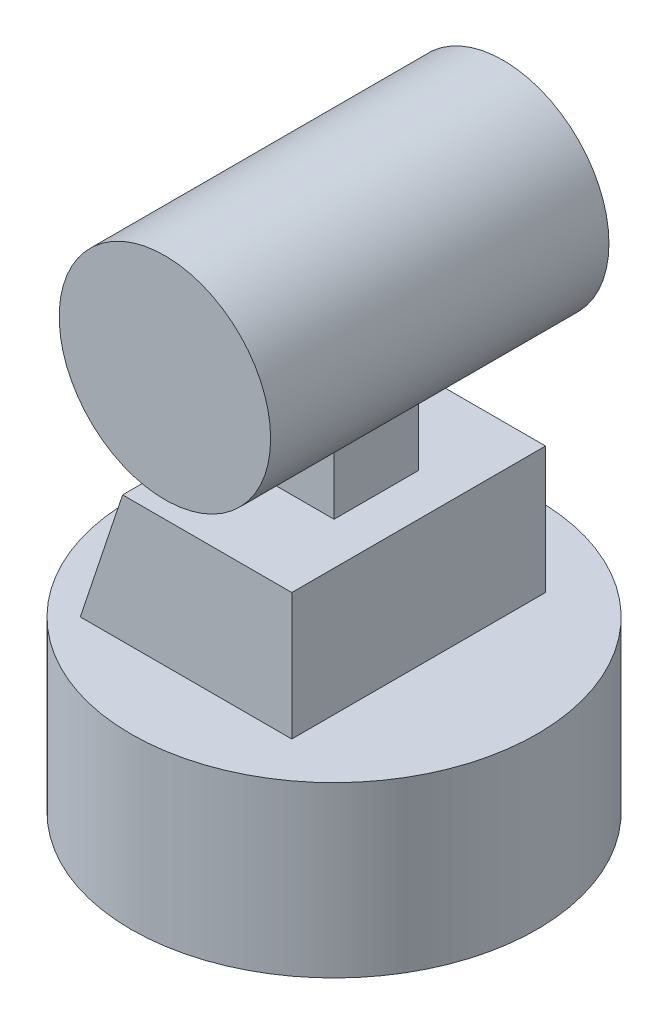
from build123d import *

# Parameters (mm, degrees)
SKETCH1_R           = 24
BOSS_EXTRUDE1_DEPTH = 20
SKETCH4_R           = 12.5
BOSS_EXTRUDE3_DEPTH = 20
BOSS_EXTRUDE5_DEPTH = 15
SKETCH6_W           = 10
SKETCH6_H           = 10
BOSS_EXTRUDE6_DEPTH = 8.043561


with BuildPart() as part:
    # Sketch1 → Boss-Extrude1 (new body)
    with BuildSketch(Plane(origin=(0, 0, 0), x_dir=(1, 0, 0), z_dir=(0, 1, 0))):
        Circle(SKETCH1_R)
    extrude(amount=BOSS_EXTRUDE1_DEPTH)

    # Sketch5 → Boss-Extrude5 (add, symmetric)
    with BuildSketch(Plane.XY):
        Polygon((-15, 20), (10, 20), (10, 35), (-10, 35), align=None)
    extrude(amount=BOSS_EXTRUDE5_DEPTH, both=True)



with BuildPart() as body_2:
    # Sketch4 → Boss-Extrude3 (new body, symmetric)
    with BuildSketch(Plane.XY):
        with Locations((0, 54.5)):
            Circle(SKETCH4_R)
    extrude(amount=BOSS_EXTRUDE3_DEPTH, both=True)


with BuildPart() as part_1:
    add(part.part)

    add(body_2.part)  # Boss-Extrude6 merges body 2
    # Sketch6 → Boss-Extrude6 (add)
    with BuildSketch(Plane(origin=(0, 35, 0), x_dir=(1, 0, 0), z_dir=(0, 1, 0))):
        Rectangle(SKETCH6_W, SKETCH6_H)
    extrude(amount=BOSS_EXTRUDE6_DEPTH)


solid = part_1.part
